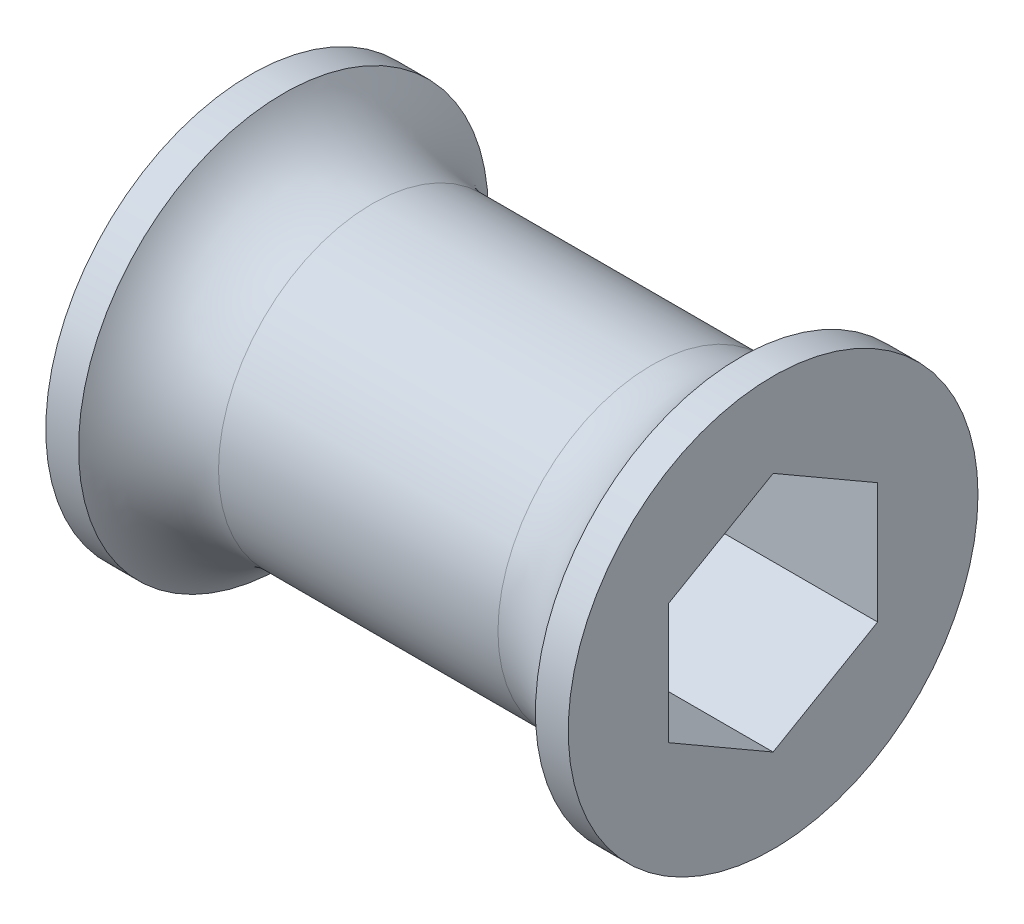
from build123d import *

# Parameters (mm, degrees)
CUT_EXTRUDE1_DEPTH = 33.385


with BuildPart() as part:
    # Sketch1 → Revolve1 (revolve)
    with BuildSketch(Plane.XY):
        with BuildLine():
            Line((0, 0), (0, 12.7))
            Line((0, 12.7), (2.032, 12.7))
            ThreePointArc((2.032, 12.7), (4.356261314, 10.375738686), (7.531261314, 9.525))
            Line((7.531261314, 9.525), (24.853738686, 9.525))
            ThreePointArc((24.853738686, 9.525), (28.028738686, 10.375738686), (30.353, 12.7))
            Line((30.353, 12.7), (32.385, 12.7))
            Line((32.385, 12.7), (32.385, 0))
            Line((32.385, 0), (0, 0))
        make_face()
    revolve(axis=Axis((0, 0, 0), (-1, 0, 0)))

    # Sketch2 → Cut-Extrude1 (cut, through all)
    with BuildSketch(Plane.ZY):
        Polygon((0, 7.478995387), (-6.477, 3.739497694), (-6.477, -3.739497694), (0, -7.478995387), (6.477, -3.739497694), (6.477, 3.739497694), align=None)
    extrude(amount=-CUT_EXTRUDE1_DEPTH, mode=Mode.SUBTRACT)


solid = part.part
